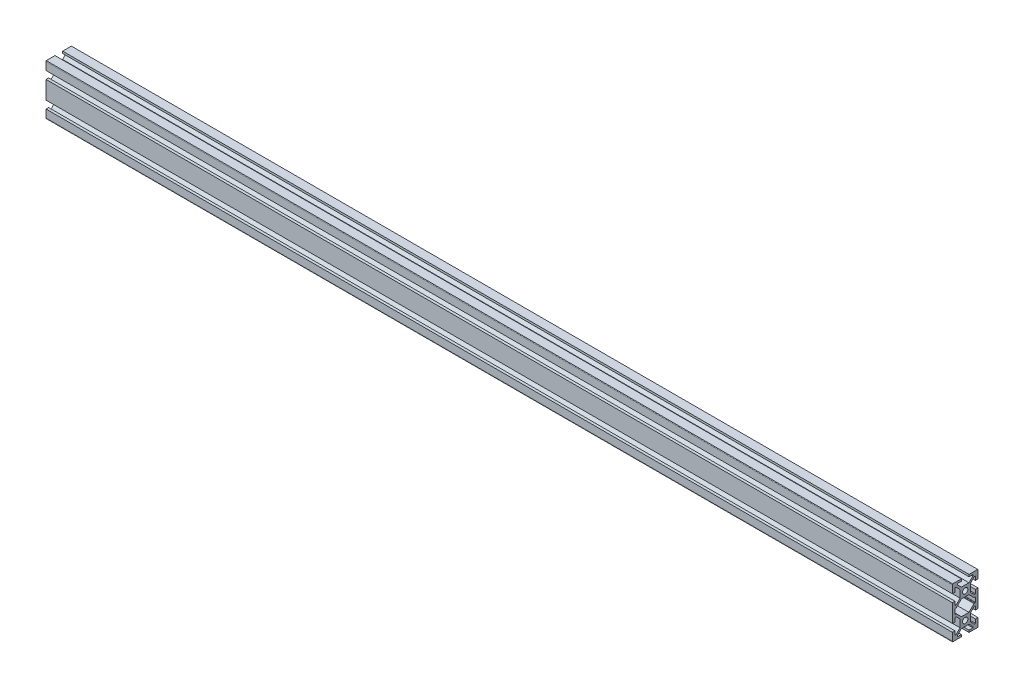
from build123d import *

# Parameters (mm, degrees)
SKETCH1_R           = 2.1
BOSS_EXTRUDE1_DEPTH = 707


with BuildPart() as part:
    # Sketch1 → Boss-Extrude1 (new body)
    with BuildSketch(Plane(origin=(0, 0, 0), x_dir=(0, 0, -1), z_dir=(1, 0, 0))):
        with BuildLine():
            Line((-10, 7), (-10, -7))
            Line((-10, -7), (-8, -7))
            Line((-8, -7), (-8, -4))
            Line((-8, -4), (-7.060660172, -4))
            Line((-7.060660172, -4), (-4, -7.060660172))
            Line((-4, -7.060660172), (-4, -12.939339828))
            Line((-4, -12.939339828), (-7.060660172, -16))
            Line((-7.060660172, -16), (-8, -16))
            Line((-8, -16), (-8, -13))
            Line((-8, -13), (-10, -13))
            Line((-10, -13), (-10, -19))
            ThreePointArc((-10, -19), (-9.948683298, -19.316227766), (-9.8, -19.6))
            Line((-9.8, -19.6), (-3, -19.6))
            Line((-3, -19.6), (-3, -18))
            Line((-3, -18), (-6, -18))
            Line((-6, -18), (-6, -17.060660172))
            Line((-6, -17.060660172), (-2.939339828, -14))
            Line((-2.939339828, -14), (2.939339828, -14))
            Line((2.939339828, -14), (6, -17.060660172))
            Line((6, -17.060660172), (6, -18))
            Line((6, -18), (3, -18))
            Line((3, -18), (3, -19.6))
            Line((3, -19.6), (9.8, -19.6))
            ThreePointArc((9.8, -19.6), (9.948683298, -19.316227766), (10, -19))
            Line((10, -19), (10, -13))
            Line((10, -13), (8, -13))
            Line((8, -13), (8, -16))
            Line((8, -16), (7.060660172, -16))
            Line((7.060660172, -16), (4, -12.939339828))
            Line((4, -12.939339828), (4, -7.060660172))
            Line((4, -7.060660172), (7.060660172, -4))
            Line((7.060660172, -4), (8, -4))
            Line((8, -4), (8, -7))
            Line((8, -7), (10, -7))
            Line((10, -7), (10, 7))
            Line((10, 7), (8, 7))
            Line((8, 7), (8, 4))
            Line((8, 4), (7.060660172, 4))
            Line((7.060660172, 4), (4, 7.060660172))
            Line((4, 7.060660172), (4, 12.939339828))
            Line((4, 12.939339828), (7.060660172, 16))
            Line((7.060660172, 16), (8, 16))
            Line((8, 16), (8, 13))
            Line((8, 13), (10, 13))
            Line((10, 13), (10, 19))
            ThreePointArc((10, 19), (9.948683298, 19.316227766), (9.8, 19.6))
            Line((9.8, 19.6), (3, 19.6))
            Line((3, 19.6), (3, 18))
            Line((3, 18), (6, 18))
            Line((6, 18), (6, 17.060660172))
            Line((6, 17.060660172), (2.939339828, 14))
            Line((2.939339828, 14), (-2.939339828, 14))
            Line((-2.939339828, 14), (-6, 17.060660172))
            Line((-6, 17.060660172), (-6, 18))
            Line((-6, 18), (-3, 18))
            Line((-3, 18), (-3, 19.6))
            Line((-3, 19.6), (-9.8, 19.6))
            ThreePointArc((-9.8, 19.6), (-9.948683298, 19.316227766), (-10, 19))
            Line((-10, 19), (-10, 13))
            Line((-10, 13), (-8, 13))
            Line((-8, 13), (-8, 16))
            Line((-8, 16), (-7.060660172, 16))
            Line((-7.060660172, 16), (-4, 12.939339828))
            Line((-4, 12.939339828), (-4, 7.060660172))
            Line((-4, 7.060660172), (-7.060660172, 4))
            Line((-7.060660172, 4), (-8, 4))
            Line((-8, 4), (-8, 7))
            Line((-8, 7), (-10, 7))
        make_face()
        with Locations((0, 10)):
            Circle(SKETCH1_R, mode=Mode.SUBTRACT)
        with Locations((0, -10)):
            Circle(SKETCH1_R, mode=Mode.SUBTRACT)
        with BuildLine():
            Line((-8, 1.7), (-8, -1.7))
            ThreePointArc((-8, -1.7), (-7.912132034, -1.912132034), (-7.7, -2))
            Line((-7.7, -2), (-7.063603897, -2))
            ThreePointArc((-7.063603897, -2), (-6.948798867, -2.02283614), (-6.851471863, -2.087867966))
            Line((-6.851471863, -2.087867966), (-2.939339828, -6))
            Line((-2.939339828, -6), (2.939339828, -6))
            Line((2.939339828, -6), (6.851471863, -2.087867966))
            ThreePointArc((6.851471863, -2.087867966), (6.948798867, -2.02283614), (7.063603897, -2))
            Line((7.063603897, -2), (7.7, -2))
            ThreePointArc((7.7, -2), (7.912132034, -1.912132034), (8, -1.7))
            Line((8, -1.7), (8, 1.7))
            ThreePointArc((8, 1.7), (7.912132034, 1.912132034), (7.7, 2))
            Line((7.7, 2), (7.063603897, 2))
            ThreePointArc((7.063603897, 2), (6.948798867, 2.02283614), (6.851471863, 2.087867966))
            Line((6.851471863, 2.087867966), (2.939339828, 6))
            Line((2.939339828, 6), (-2.939339828, 6))
            Line((-2.939339828, 6), (-6.851471863, 2.087867966))
            ThreePointArc((-6.851471863, 2.087867966), (-6.948798867, 2.02283614), (-7.063603897, 2))
            Line((-7.063603897, 2), (-7.7, 2))
            ThreePointArc((-7.7, 2), (-7.912132034, 1.912132034), (-8, 1.7))
        make_face(mode=Mode.SUBTRACT)
    extrude(amount=BOSS_EXTRUDE1_DEPTH)


solid = part.part
